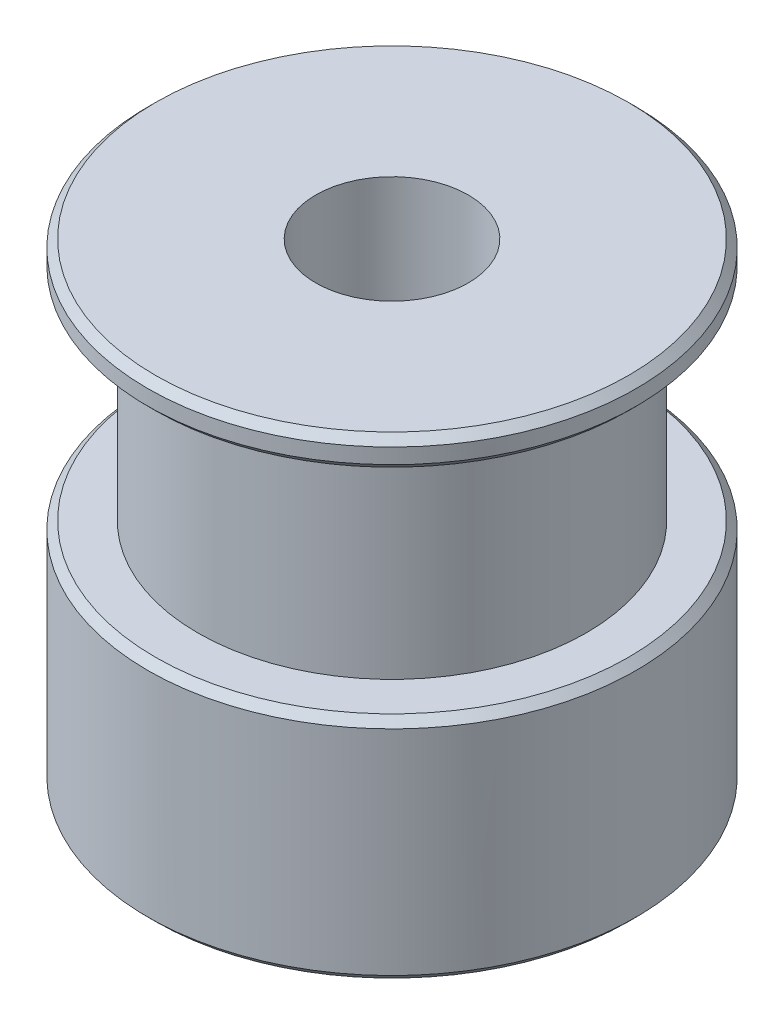
from build123d import *

# Parameters (mm, degrees)
CHAMFER1_SIZE = 0.25


with BuildPart() as part:
    # Sketch4 → Revolve2 (revolve)
    with BuildSketch(Plane.XY):
        Polygon((2.5, 0), (8, 0), (8, 7.5), (6.366197724, 7.5), (6.366197724, 14.5), (8, 14.5), (8, 15.5), (2.5, 15.5), align=None)
    revolve(axis=Axis((0, 0, 0), (0, 1, 0)))

    # Chamfer1
    chamfer1_edges = [part.edges().sort_by_distance(p)[0] for p in [
        (-8, 15.5, 0),
        (-8, 14.5, 0),
        (-8, 7.5, 0),
        (-8, 0, 0),
    ]]
    chamfer(chamfer1_edges, length=CHAMFER1_SIZE)


solid = part.part
